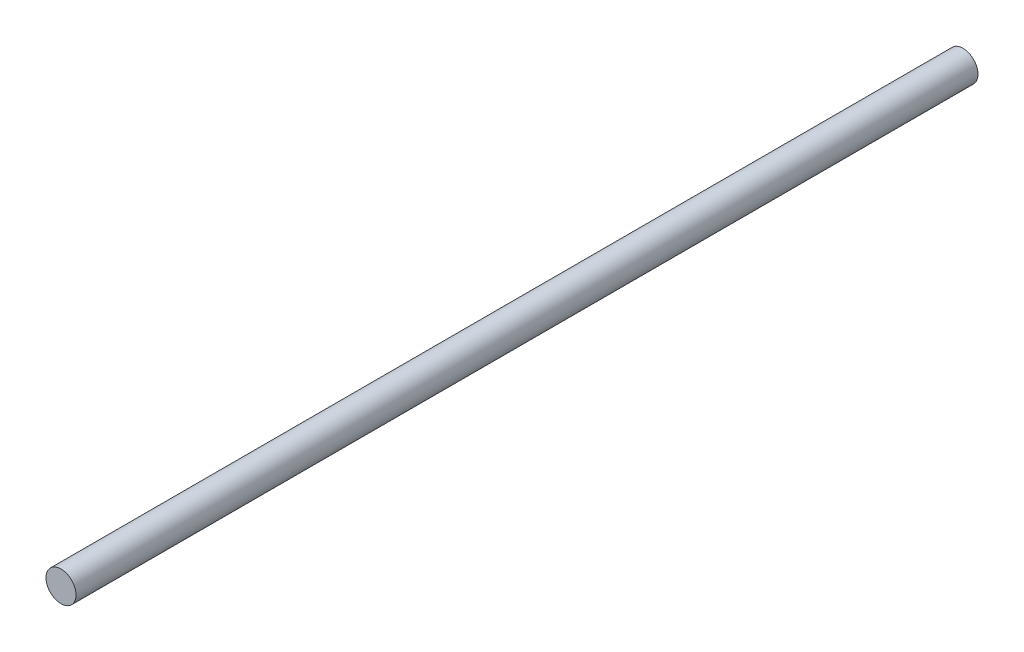
from build123d import *

# Parameters (mm, degrees)
SKETCH_1_R      = 1.5
EXTRUDE_1_DEPTH = 90


with BuildPart() as part:
    # Эскиз1 → Бобышка-Вытянуть1 (new body)
    with BuildSketch(Plane.XY):
        Circle(SKETCH_1_R)
    extrude(amount=EXTRUDE_1_DEPTH)


solid = part.part
